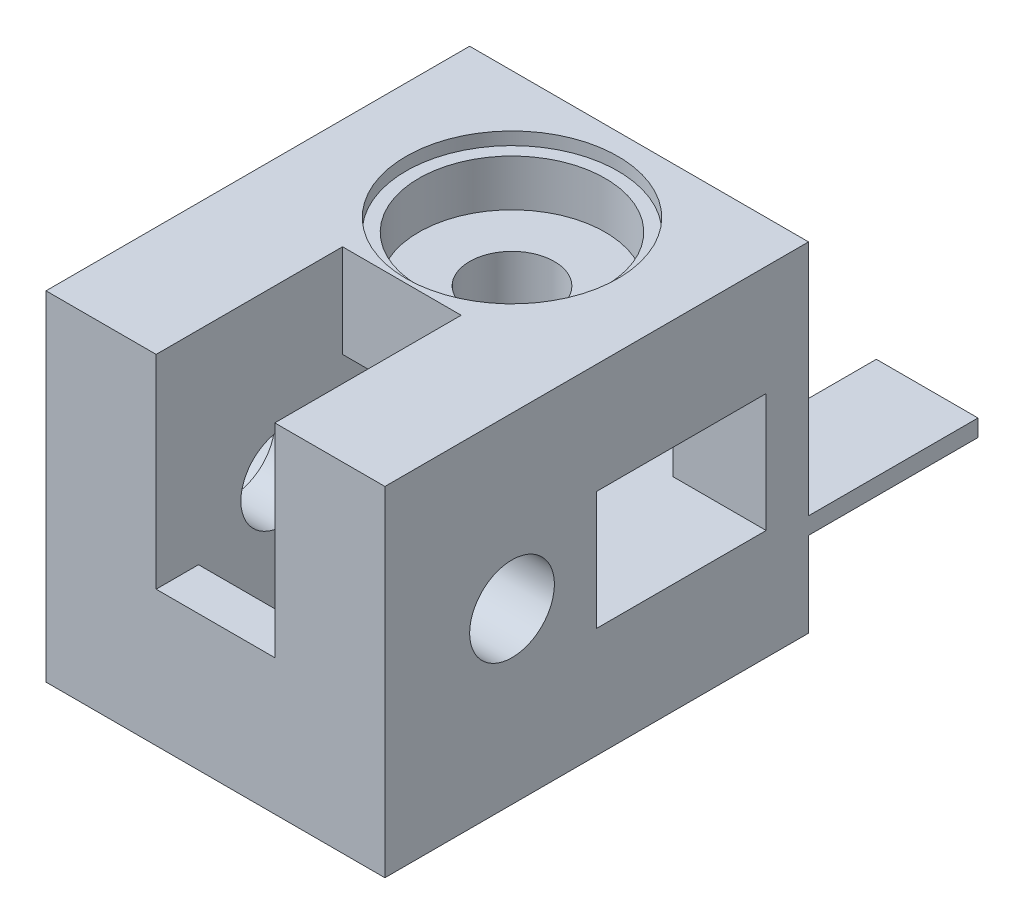
from build123d import *

# Parameters (mm, degrees)
ESQUISSE1_W              = 40
ESQUISSE1_H              = 40
BOSS_EXTRU_1_DEPTH       = 50
ESQUISSE2_R              = 5
ENL_V_MAT_EXTRU_1_DEPTH  = 41
ESQUISSE3_R              = 5
ENL_V_MAT_EXTRU_2_DEPTH  = 41
ESQUISSE4_W              = 22
ESQUISSE4_H              = 14
ENL_V_MAT_EXTRU_3_DEPTH  = 29
ESQUISSE5_W              = 14
ESQUISSE5_H              = 20
ENL_V_MAT_EXTRU_4_DEPTH  = 29
ESQUISSE6_W              = 20
ESQUISSE6_H              = 14
ENL_V_MAT_EXTRU_5_DEPTH  = 24
ESQUISSE7_W              = 14
ESQUISSE7_H              = 22
ENL_V_MAT_EXTRU_6_DEPTH  = 24
ESQUISSE10_R             = 11
ENL_V_MAT_EXTRU_9_DEPTH  = 7
ESQUISSE11_R             = 12.5
ENL_V_MAT_EXTRU_10_DEPTH = 1.5
ESQUISSE14_R             = 11
ENL_V_MAT_EXTRU_11_DEPTH = 7
ESQUISSE15_R             = 12.5
ENL_V_MAT_EXTRU_12_DEPTH = 1.5
BOSS_EXTRU_2_DEPTH       = 20


with BuildPart() as part:
    # Esquisse1 → Boss.-Extru.1 (new body)
    with BuildSketch(Plane.XY):
        with Locations((-20, 20)):
            Rectangle(ESQUISSE1_W, ESQUISSE1_H)
    extrude(amount=BOSS_EXTRU_1_DEPTH)

    # Esquisse2 → Enlèv. mat.-Extru.1 (cut, through all)
    with BuildSketch(Plane(origin=(0, 40, 0), x_dir=(1, 0, 0), z_dir=(0, 1, 0))):
        with Locations(Location((-20, -15, 0), (0, 0, 270))):  # turned: the seam where the file's is
            Circle(ESQUISSE2_R)
    extrude(amount=-ENL_V_MAT_EXTRU_1_DEPTH, mode=Mode.SUBTRACT)

    # Esquisse3 → Enlèv. mat.-Extru.2 (cut, through all)
    with BuildSketch(Plane.ZY.offset(40)):
        with Locations((35, 20)):
            Circle(ESQUISSE3_R)
    extrude(amount=-ENL_V_MAT_EXTRU_2_DEPTH, mode=Mode.SUBTRACT)

    # Esquisse4 → Enlèv. mat.-Extru.3 (cut)
    with BuildSketch(Plane.ZY.offset(40)):
        with Locations((11, 20)):
            Rectangle(ESQUISSE4_W, ESQUISSE4_H)
    extrude(amount=-ENL_V_MAT_EXTRU_3_DEPTH, mode=Mode.SUBTRACT)

    # Esquisse5 → Enlèv. mat.-Extru.4 (cut)
    with BuildSketch(Plane.XZ):
        with Locations((-20, 35)):
            Rectangle(ESQUISSE5_W, ESQUISSE5_H)
    extrude(amount=-ENL_V_MAT_EXTRU_4_DEPTH, mode=Mode.SUBTRACT)

    # Esquisse6 → Enlèv. mat.-Extru.5 (cut)
    with BuildSketch(Plane(origin=(0, 0, 0), x_dir=(0, 0, -1), z_dir=(1, 0, 0))):
        with Locations((-15, 20)):
            Rectangle(ESQUISSE6_W, ESQUISSE6_H)
    extrude(amount=-ENL_V_MAT_EXTRU_5_DEPTH, mode=Mode.SUBTRACT)

    # Esquisse7 → Enlèv. mat.-Extru.6 (cut)
    with BuildSketch(Plane(origin=(0, 40, 0), x_dir=(1, 0, 0), z_dir=(0, 1, 0))):
        with Locations((-20, -39)):
            Rectangle(ESQUISSE7_W, ESQUISSE7_H)
    extrude(amount=-ENL_V_MAT_EXTRU_6_DEPTH, mode=Mode.SUBTRACT)

    # Esquisse10 → Enlèv. mat.-Extru.9 (cut)
    with BuildSketch(Plane(origin=(0, 40, 0), x_dir=(1, 0, 0), z_dir=(0, 1, 0))):
        with Locations(Location((-20, -15, 0), (0, 0, 270))):  # turned: the seam where the file's is
            Circle(ESQUISSE10_R)
    extrude(amount=-ENL_V_MAT_EXTRU_9_DEPTH, mode=Mode.SUBTRACT)

    # Esquisse11 → Enlèv. mat.-Extru.10 (cut)
    with BuildSketch(Plane(origin=(0, 40, 0), x_dir=(1, 0, 0), z_dir=(0, 1, 0))):
        with Locations(Location((-20, -15, 0), (0, 0, 270))):  # turned: the seam where the file's is
            Circle(ESQUISSE11_R)
    extrude(amount=-ENL_V_MAT_EXTRU_10_DEPTH, mode=Mode.SUBTRACT)

    # Esquisse14 → Enlèv. mat.-Extru.11 (cut)
    with BuildSketch(Plane.ZY.offset(40)):
        with Locations((35, 20)):
            Circle(ESQUISSE14_R)
    extrude(amount=-ENL_V_MAT_EXTRU_11_DEPTH, mode=Mode.SUBTRACT)

    # Esquisse15 → Enlèv. mat.-Extru.12 (cut)
    with BuildSketch(Plane.ZY.offset(40)):
        with Locations((35, 20)):
            Circle(ESQUISSE15_R)
    extrude(amount=-ENL_V_MAT_EXTRU_12_DEPTH, mode=Mode.SUBTRACT)

    # Esquisse16 → Boss.-Extru.2 (add)
    with BuildSketch(Plane(origin=(0, 0, 0), x_dir=(-1, 0, 0), z_dir=(0, 0, -1))):
        Polygon((12, 0), (12, 12), (0, 12), (0, 10), (10, 10), (10, 0), align=None)
    extrude(amount=BOSS_EXTRU_2_DEPTH)


solid = part.part
